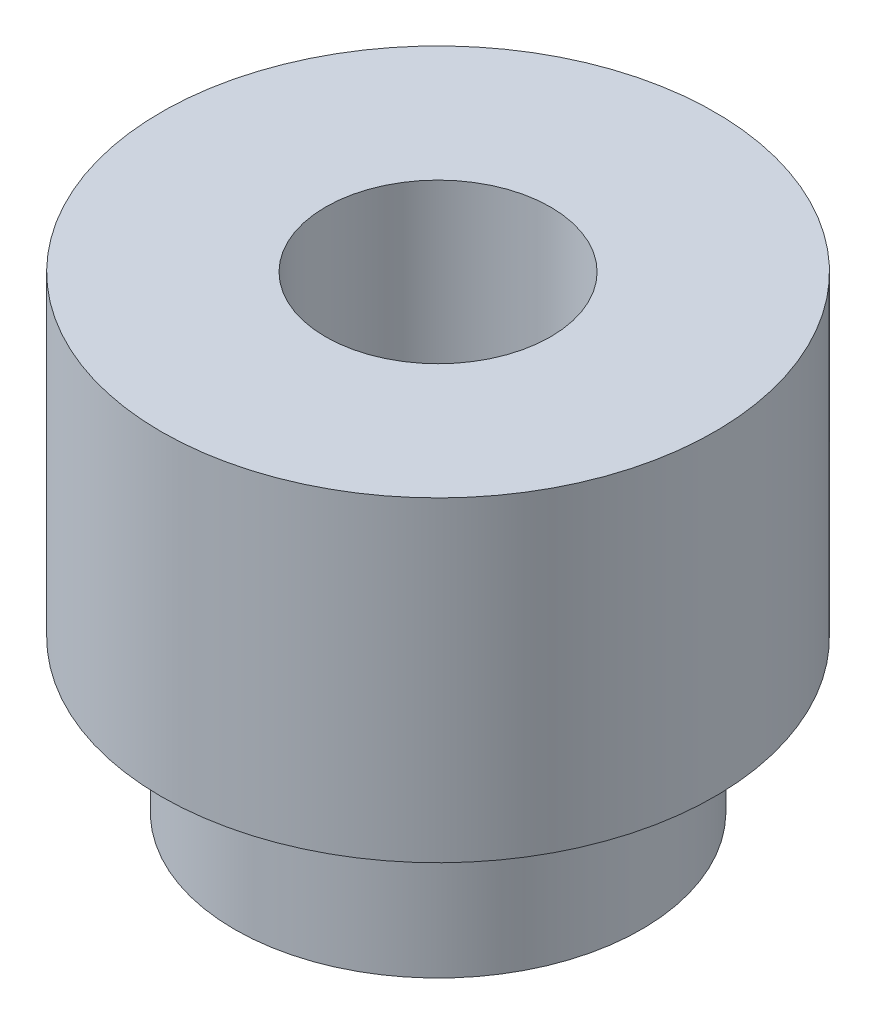
from build123d import *

# Parameters (mm, degrees)
SKETCH1_R                 = 2.045
BOSS_EXTRUDE1_DEPTH       = 1.524
SKETCH2_R                 = 2.7813
BOSS_EXTRUDE2_DEPTH       = 3.175
F_4_40_TAPPED_HOLE1_D     = 2.2606
F_4_40_TAPPED_HOLE1_DEPTH = 7.62
F_4_40_TAPPED_HOLE1_TIP   = 0.679152758


with BuildPart() as part:
    # Sketch1 → Boss-Extrude1 (new body)
    with BuildSketch(Plane(origin=(0, 0, 0), x_dir=(1, 0, 0), z_dir=(0, 1, 0))):
        Circle(SKETCH1_R)
    extrude(amount=BOSS_EXTRUDE1_DEPTH)

    # Sketch2 → Boss-Extrude2 (add)
    with BuildSketch(Plane(origin=(0, 1.524, 0), x_dir=(1, 0, 0), z_dir=(0, 1, 0))):
        Circle(SKETCH2_R)
    extrude(amount=BOSS_EXTRUDE2_DEPTH)

    # #4-40 Tapped Hole1
    with Locations(Plane(origin=(0, 4.699, 0), x_dir=(1, 0, 0), z_dir=(0, 1, 0))):
        with Locations((0, 0)):
            Hole(F_4_40_TAPPED_HOLE1_D / 2, depth=F_4_40_TAPPED_HOLE1_DEPTH)
            with Locations((0, 0, -(F_4_40_TAPPED_HOLE1_DEPTH + F_4_40_TAPPED_HOLE1_TIP / 2))):  # 118° drill point
                Cone(0, F_4_40_TAPPED_HOLE1_D / 2, F_4_40_TAPPED_HOLE1_TIP, mode=Mode.SUBTRACT)


solid = part.part
